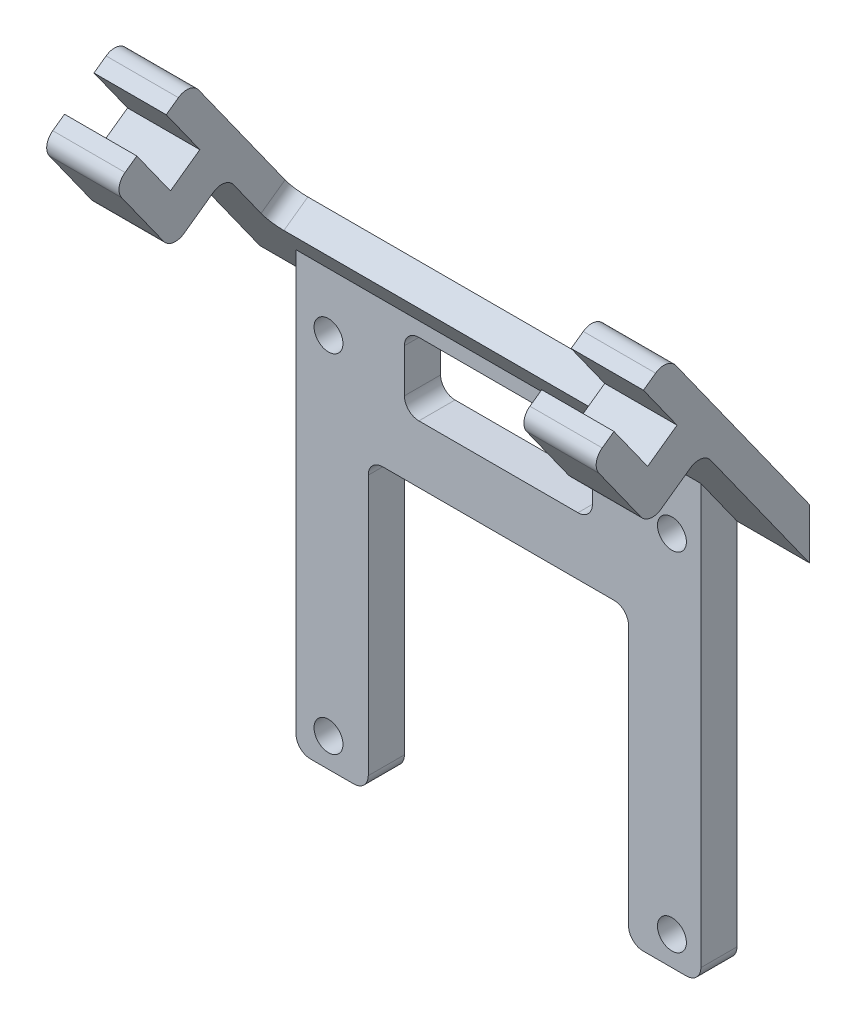
from build123d import *

# Parameters (mm, degrees)
SALIENTE_EXTRUIR1_DEPTH      = 2.5
SALIENTE_EXTRUIR2_DEPTH      = 19
SALIENTE_EXTRUIR2_DEPTH_BACK = 19
CROQUIS3_R                   = 1
CORTAR_EXTRUIR2_DEPTH        = 2.5
CROQUIS2_W                   = 13
CROQUIS2_H                   = 5
CORTAR_EXTRUIR1_DEPTH        = 3
REDONDEO1_R                  = 1
CROQUIS7_W                   = 28
CROQUIS7_H                   = 15.287444166
CORTAR_EXTRUIR3_DEPTH        = 2.5
CROQUIS8_W                   = 5
CROQUIS8_H                   = 3
CORTAR_EXTRUIR4_DEPTH        = 2.5
REDONDEO2_R                  = 1
CROQUIS9_W                   = 5
CROQUIS9_H                   = 3
SALIENTE_EXTRUIR3_DEPTH      = 4.5
CROQUIS10_W                  = 5
CROQUIS10_H                  = 2
SALIENTE_EXTRUIR4_DEPTH      = 4
REDONDEO3_R                  = 1
REDONDEO3_OF_SIMETR_A3_R     = 1
REDONDEO4_R                  = 1


with BuildPart() as part:
    # Croquis1 → Saliente-Extruir1 (new body)
    with BuildSketch(Plane.XY):
        Polygon((-9, -15), (-14, -15), (-14, 15), (14, 15), (14, -15), (9, -15), (9, 5), (-9, 5), align=None)
    extrude(amount=SALIENTE_EXTRUIR1_DEPTH)

    # Croquis6 → Saliente-Extruir2 (add, two sides)
    with BuildSketch(Plane(origin=(0, 0, 0), x_dir=(0, 0, -1), z_dir=(1, 0, 0))) as saliente_extruir2_sk:
        Polygon((0, 14.99808723), (0, 11.497275395), (-11.558640634, 27.693398632), (-11.558640634, 31.194210467), align=None)
    extrude(amount=SALIENTE_EXTRUIR2_DEPTH)
    extrude(saliente_extruir2_sk.sketch, amount=-SALIENTE_EXTRUIR2_DEPTH_BACK)

    # Croquis3 → Cortar-Extruir2 (cut)
    with BuildSketch(Plane.XY.offset(2.5)):
        with Locations((-11.75, -13)):
            Circle(CROQUIS3_R)
        with Locations((-11.75, 11)):
            Circle(CROQUIS3_R)
        with Locations((12, -13)):
            Circle(CROQUIS3_R)
        with Locations((12, 11)):
            Circle(CROQUIS3_R)
    extrude(amount=-CORTAR_EXTRUIR2_DEPTH, mode=Mode.SUBTRACT)

    # Croquis2 → Cortar-Extruir1 (cut)
    with BuildSketch(Plane.XY.offset(2.5)):
        with Locations((0, 11.5)):
            Rectangle(CROQUIS2_W, CROQUIS2_H)
    extrude(amount=-CORTAR_EXTRUIR1_DEPTH, mode=Mode.SUBTRACT)

    # Redondeo1
    redondeo1_edges = [part.edges().sort_by_distance(p)[0] for p in [
        (14, -15, 1.25),
        (9, -15, 1.25),
        (9, 5, 1.25),
        (-9, 5, 1.25),
        (-9, -15, 1.25),
        (-14, -15, 1.25),
        (-6.5, 9, 1.25),
        (-6.5, 14, 1.25),
        (6.5, 14, 1.25),
        (6.5, 9, 1.25),
    ]]
    fillet(redondeo1_edges, radius=REDONDEO1_R)

    # Croquis7 → Cortar-Extruir3 (cut)
    with BuildSketch(Plane(origin=(0, 5.061109194, -7.091694501), x_dir=(-1, 0, 0), z_dir=(0, 0.580904735, -0.813971553))):
        with Locations((0, 24.46194693)):
            Rectangle(CROQUIS7_W, CROQUIS7_H)
    extrude(amount=-CORTAR_EXTRUIR3_DEPTH, mode=Mode.SUBTRACT)

    # Croquis8 → Cortar-Extruir4 (cut)
    with BuildSketch(Plane(origin=(0, 5.061109194, -7.091694501), x_dir=(-1, 0, 0), z_dir=(0, 0.580904735, -0.813971553))):
        with Locations((-16.5, 30.605669013)):
            Rectangle(CROQUIS8_W, CROQUIS8_H)
    cortar_extruir4 = extrude(amount=-CORTAR_EXTRUIR4_DEPTH, mode=Mode.SUBTRACT)

    # Simetría1: Cortar-Extruir4 across plane
    add(cortar_extruir4.mirror(Plane(origin=(0, 0, 0), x_dir=(0, 0, 1), z_dir=(1, 0, 0))), mode=Mode.SUBTRACT)

    # Redondeo2
    redondeo2_edges = [part.edges().sort_by_distance(p)[0] for p in [
        (16.5, 28.752295807, 9.815926431),
        (-16.5, 28.752295807, 9.815926431),
    ]]
    fillet(redondeo2_edges, radius=REDONDEO2_R)

    # Croquis9 → Saliente-Extruir3 (add)
    with BuildSketch(Plane(origin=(0, 3.879759153, -5.436370882), x_dir=(1, 0, 0), z_dir=(0, -0.580904735, 0.813971553))):
        with Locations((-16.5, 23.605669013)):
            Rectangle(CROQUIS9_W, CROQUIS9_H)
    saliente_extruir3 = extrude(amount=SALIENTE_EXTRUIR3_DEPTH)

    # Croquis10 → Saliente-Extruir4 (add)
    with BuildSketch(Plane(origin=(0, 20.4353004, 14.584001994), x_dir=(1, 0, 0), z_dir=(0, 0.813971553, 0.580904735))):
        with Locations((-16.5, 3.178821712)):
            Rectangle(CROQUIS10_W, CROQUIS10_H)
    saliente_extruir4 = extrude(amount=SALIENTE_EXTRUIR4_DEPTH)

    # Redondeo3
    redondeo3_edges = [part.edges().sort_by_distance(p)[0] for p in [
        (-16.5, 21.873144894, 7.404916908),
        (-16.5, 19.259073588, 11.067788897),
        (-16.5, 24.956874461, 15.134122039),
    ]]
    fillet(redondeo3_edges, radius=REDONDEO3_R)

    # Simetría3: Saliente-Extruir3, Saliente-Extruir4 across plane
    add(saliente_extruir3.mirror(Plane(origin=(0, 0, 0), x_dir=(0, 0, 1), z_dir=(1, 0, 0))))
    add(saliente_extruir4.mirror(Plane(origin=(0, 0, 0), x_dir=(0, 0, 1), z_dir=(1, 0, 0))))

    # Redondeo3 of Simetría3
    redondeo3_of_simetr_a3_edges = [part.edges().sort_by_distance(p)[0] for p in [
        (16.5, 21.873144894, 7.404916908),
        (16.5, 19.259073588, 11.067788897),
        (16.5, 24.956874461, 15.134122039),
    ]]
    fillet(redondeo3_of_simetr_a3_edges, radius=REDONDEO3_OF_SIMETR_A3_R)

    # Redondeo4
    redondeo4_edges = [part.edges().sort_by_distance(p)[0] for p in [
        (14, 18.159990774, 3.505753749),
        (-14, 18.159990774, 3.505753749),
    ]]
    fillet(redondeo4_edges, radius=REDONDEO4_R)


solid = part.part
